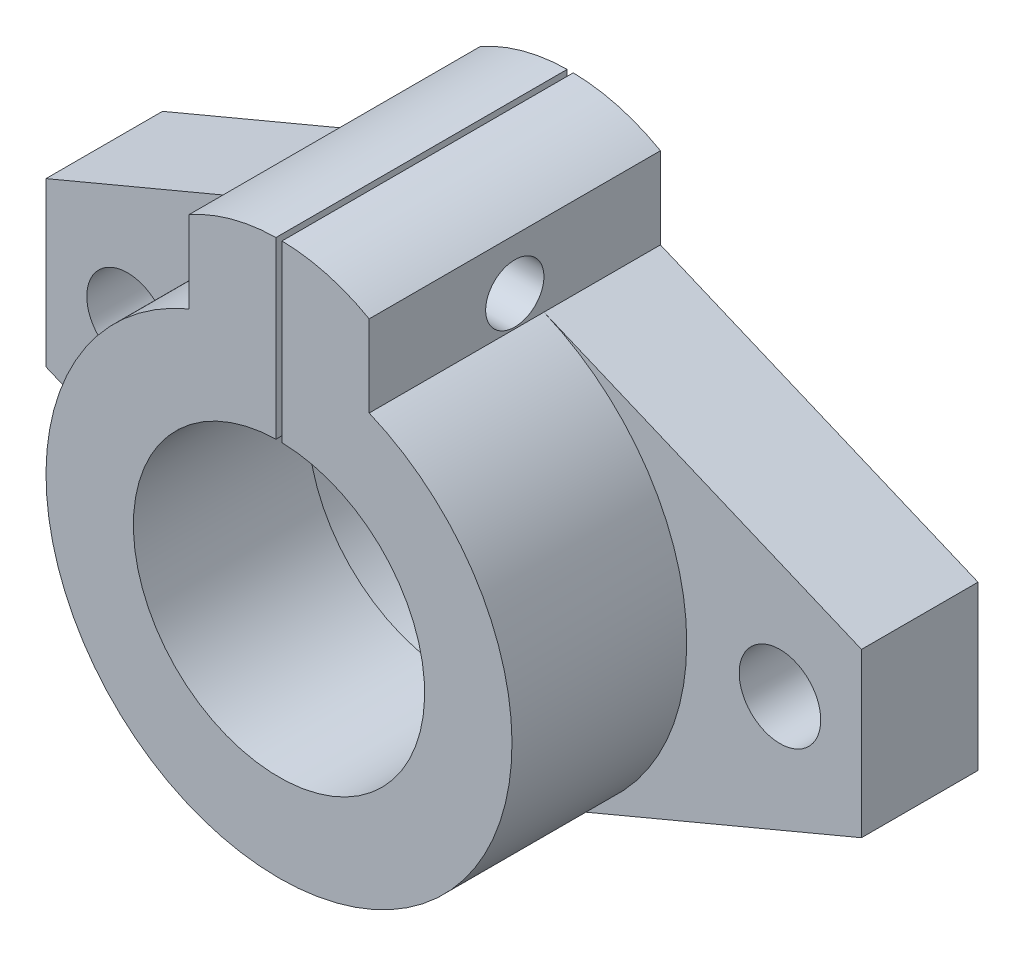
from build123d import *

# Parameters (mm, degrees)
SKETCH_1_R          = 3.5
SKETCH_1_R_2        = 13
EXTRUDE_2_DEPTH     = 10
SKETCH_2_R          = 12.5
EXTRUDE_3_DEPTH     = 15
SKETCH_3_W          = 0.517195108
SKETCH_3_H          = 18.726193104
CUT_EXTRUDE_1_DEPTH = 26
SKETCH_4_R          = 2.5
CUT_EXTRUDE_2_DEPTH = 43.740275714


with BuildPart() as part:
    # 草图1 → 凸台-拉伸2 (new body)
    with BuildSketch(Plane.XY):
        with BuildLine():
            Line((-35, -7), (-7.740275714, -18.44147857))
            ThreePointArc((-7.740275714, -18.44147857), (0, -20), (7.740275714, -18.44147857))
            Line((7.740275714, -18.44147857), (35, -7))
            Line((35, -7), (35, 7))
            Line((35, 7), (7.740275714, 18.44147857))
            Line((7.740275714, 18.44147857), (7.740275714, 25.44147857))
            ThreePointArc((7.740275714, 25.44147857), (0, 27.494244152), (-7.740275714, 25.44147857))
            Line((-7.740275714, 25.44147857), (-7.740275714, 18.44147857))
            Line((-7.740275714, 18.44147857), (-35, 7))
            Line((-35, 7), (-35, -7))
        make_face()
        with Locations((-28, 0)):
            Circle(SKETCH_1_R, mode=Mode.SUBTRACT)
        Circle(SKETCH_1_R_2, mode=Mode.SUBTRACT)
        with Locations((28, 0)):
            Circle(SKETCH_1_R, mode=Mode.SUBTRACT)
    extrude(amount=EXTRUDE_2_DEPTH)

    # 草图2 → 凸台-拉伸3 (add)
    with BuildSketch(Plane.XY.offset(10)):
        with BuildLine():
            Line((-7.740275714, 18.44147857), (-7.740275714, 25.44147857))
            ThreePointArc((-7.740275714, 25.44147857), (0, 27.494244152), (7.740275714, 25.44147857))
            Line((7.740275714, 25.44147857), (7.740275714, 18.44147857))
            ThreePointArc((7.740275714, 18.44147857), (0, -20), (-7.740275714, 18.44147857))
        make_face()
        Circle(SKETCH_2_R, mode=Mode.SUBTRACT)
    extrude(amount=EXTRUDE_3_DEPTH)

    # 草图3 → 切除-拉伸1 (cut, through all)
    with BuildSketch(Plane.XY.offset(25)):
        with Locations((0, 21.741202931)):
            Rectangle(SKETCH_3_W, SKETCH_3_H)
    extrude(amount=-CUT_EXTRUDE_1_DEPTH, mode=Mode.SUBTRACT)

    # 草图4 → 切除-拉伸2 (cut, through all)
    with BuildSketch(Plane(origin=(7.740275714, 0, 0), x_dir=(0, 0, -1), z_dir=(1, 0, 0))):
        with Locations((-12.5, 21.086423576)):
            Circle(SKETCH_4_R)
    extrude(amount=-CUT_EXTRUDE_2_DEPTH, mode=Mode.SUBTRACT)


solid = part.part
